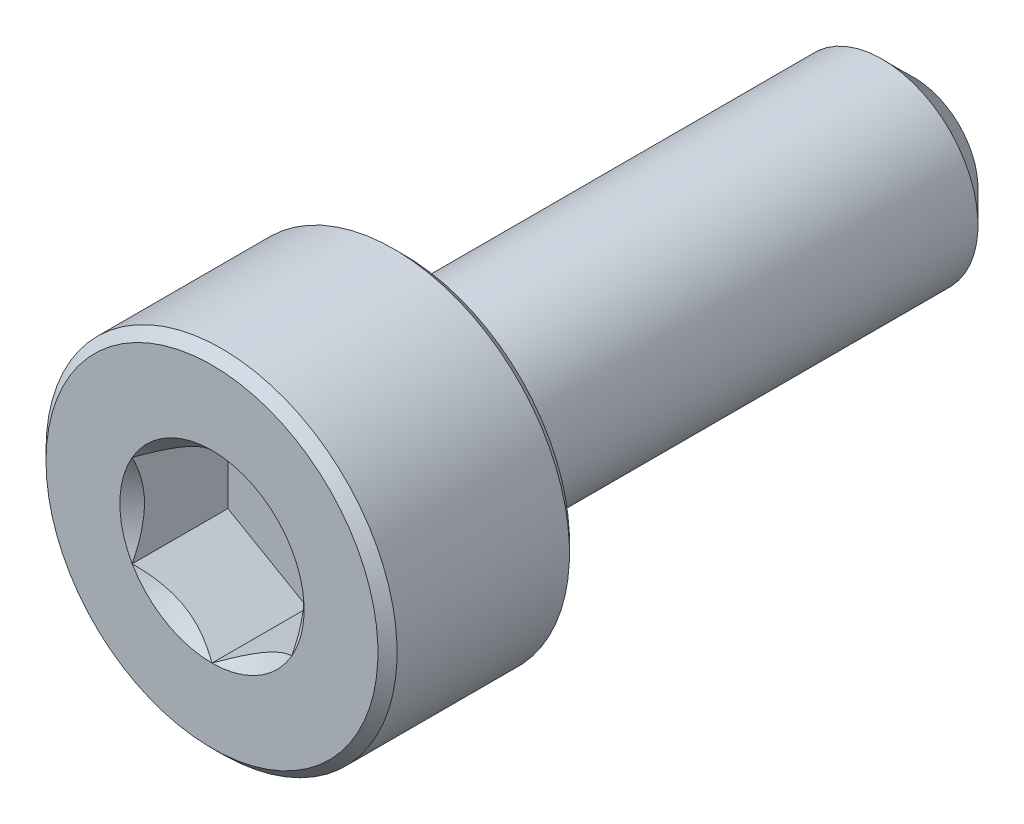
from build123d import *

# Parameters (mm, degrees)
CUT_EXTRUDE1_START = -1.5
CUT_EXTRUDE1_DEPTH = 1.5
SKETCH4_R          = 1.443375673
CUT_EXTRUDE2_DEPTH = 0.5
CUT_EXTRUDE2_TAPER = 45


with BuildPart() as part:
    # Sketch2 → Revolve1 (revolve)
    with BuildSketch(Plane(origin=(0, 0, 0), x_dir=(0, 0, -1), z_dir=(1, 0, 0))):
        Polygon((-5.35, 2.75), (-2.65, 2.75), (-2.5, 2.6), (-2.5, 1.5), (5, 1.5), (5.5, 1), (5.5, 0), (-5.5, 0), (-5.5, 2.6), align=None)
    revolve(axis=Axis((0, 0, -5.5), (0, 0, 1)))

    # Sketch3 → Cut-Extrude1 (cut)
    with BuildSketch(Plane.XY.offset(5.5).offset(CUT_EXTRUDE1_START)):
        Polygon((0, 1.443375673), (-1.25, 0.721687836), (-1.25, -0.721687836), (0, -1.443375673), (1.25, -0.721687836), (1.25, 0.721687836), align=None)
    extrude(amount=CUT_EXTRUDE1_DEPTH, mode=Mode.SUBTRACT)

    # Sketch4 → Cut-Extrude2 (cut)
    with BuildSketch(Plane.XY.offset(5.5)):
        Circle(SKETCH4_R)
    extrude(amount=-CUT_EXTRUDE2_DEPTH, taper=CUT_EXTRUDE2_TAPER, mode=Mode.SUBTRACT)


solid = part.part
